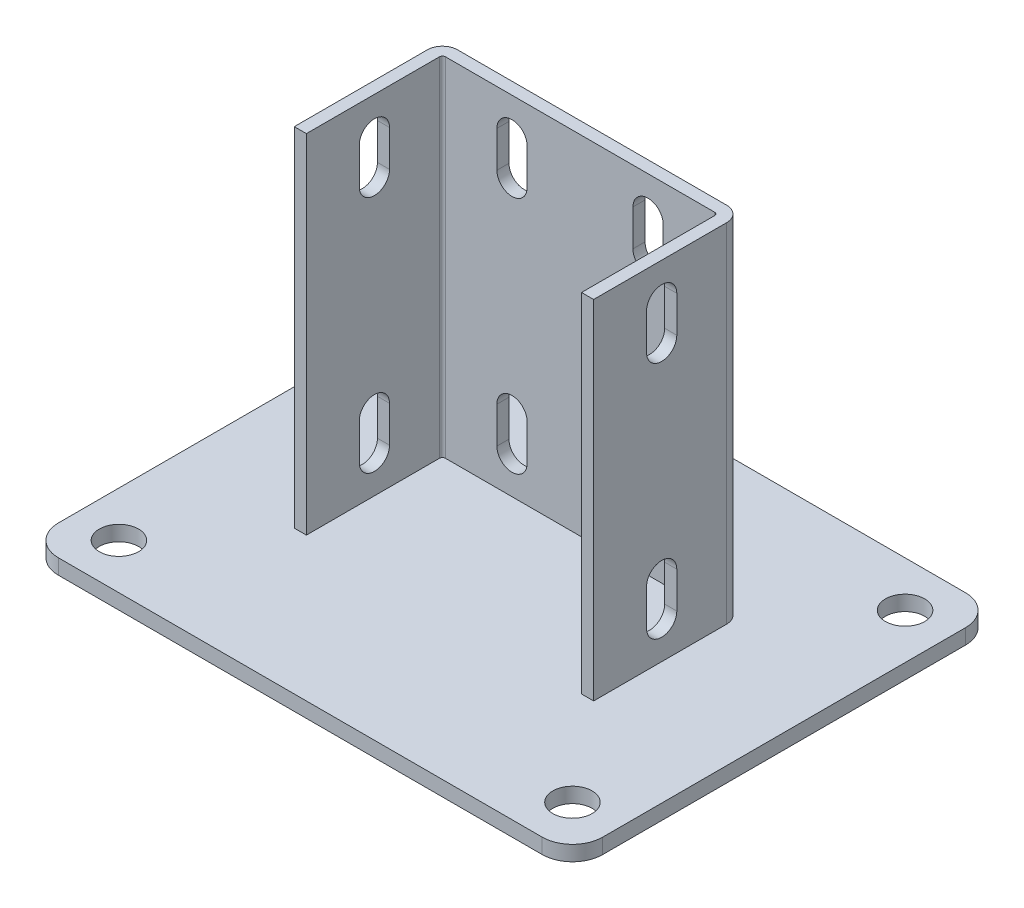
from build123d import *

# Parameters (mm, degrees)
SKETCH_2_W          = 180
SKETCH_2_H          = 140
EXTRUDE_1_DEPTH     = 5
EXTRUDE_1_2_DEPTH   = 115
EXTRUDE_2_DEPTH     = 2
CUT_EXTRUDE_1_DEPTH = 140.5
SKETCH_6_R          = 6.5
CUT_EXTRUDE_2_DEPTH = 6
FILLET_1_R          = 10
CUT_EXTRUDE_3_REACH = 98.5


with BuildPart() as part:
    # Эскиз2 → Extrude 1 (new body)
    with BuildSketch(Plane(origin=(0, 0, 0), x_dir=(1, 0, 0), z_dir=(0, 1, 0))):
        Rectangle(SKETCH_2_W, SKETCH_2_H)
    extrude(amount=EXTRUDE_1_DEPTH)

    # Эскиз3 → Extrude 1 2 (add)
    with BuildSketch(Plane(origin=(0, 5, 0), x_dir=(1, 0, 0), z_dir=(0, 1, 0))):
        with BuildLine():
            Line((-45.5, -22.5), (-45.5, 21.5))
            ThreePointArc((-45.5, 21.5), (-45.207106781, 22.207106781), (-44.5, 22.5))
            Line((-44.5, 22.5), (44.5, 22.5))
            ThreePointArc((44.5, 22.5), (45.207106781, 22.207106781), (45.5, 21.5))
            Line((45.5, 21.5), (45.5, -22.5))
            Line((45.5, -22.5), (49.5, -22.5))
            Line((49.5, -22.5), (49.5, 21.5))
            ThreePointArc((49.5, 21.5), (48.035533906, 25.035533906), (44.5, 26.5))
            Line((44.5, 26.5), (-44.5, 26.5))
            ThreePointArc((-44.5, 26.5), (-48.035533906, 25.035533906), (-49.5, 21.5))
            Line((-49.5, 21.5), (-49.5, -22.5))
            Line((-49.5, -22.5), (-45.5, -22.5))
        make_face()
    extrude(amount=EXTRUDE_1_2_DEPTH)

    # Эскиз4 → Бобышка-Вытянуть2 (add, symmetric)
    with BuildSketch(Plane(origin=(0, 0, 0), x_dir=(0, 0, -1), z_dir=(1, 0, 0))):
        Polygon((26.5, 71.683956091), (65, 5), (26.5, 5), align=None)
    extrude(amount=EXTRUDE_2_DEPTH, both=True)

    # Эскиз5 → Вырез-Вытянуть1 (cut, through all)
    with BuildSketch(Plane(origin=(49.5, 0, 0), x_dir=(0, 0, -1), z_dir=(1, 0, 0))):
        with BuildLine():
            Line((5, 108), (5, 96))
            ThreePointArc((5, 96), (0, 91), (-5, 96))
            Line((-5, 96), (-5, 108))
            ThreePointArc((-5, 108), (0, 113), (5, 108))
        make_face()
        with BuildLine():
            Line((5, 29), (5, 17))
            ThreePointArc((5, 17), (0, 12), (-5, 17))
            Line((-5, 17), (-5, 29))
            ThreePointArc((-5, 29), (0, 34), (5, 29))
        make_face()
    extrude(amount=-CUT_EXTRUDE_1_DEPTH, mode=Mode.SUBTRACT)

    # Эскиз6 → Вырез-Вытянуть2 (cut, through all)
    with BuildSketch(Plane(origin=(0, 5, 0), x_dir=(1, 0, 0), z_dir=(0, 1, 0))):
        with Locations(Location((-75, 55, 0), (0, 0, 270))):  # turned: the seam where the file's is
            Circle(SKETCH_6_R)
        with Locations(Location((-75, -55, 0), (0, 0, 270))):  # turned: the seam where the file's is
            Circle(SKETCH_6_R)
        with Locations(Location((75, 55, 0), (0, 0, 270))):  # turned: the seam where the file's is
            Circle(SKETCH_6_R)
        with Locations(Location((75, -55, 0), (0, 0, 270))):  # turned: the seam where the file's is
            Circle(SKETCH_6_R)
    extrude(amount=-CUT_EXTRUDE_2_DEPTH, mode=Mode.SUBTRACT)

    # Скругление1
    fillet_1_edges = [part.edges().sort_by_distance(p)[0] for p in [
        (90, 2.5, 70),
        (-90, 2.5, 70),
        (-90, 2.5, -70),
        (90, 2.5, -70),
    ]]
    fillet(fillet_1_edges, radius=FILLET_1_R)

    # Эскиз8 → Вырез-Вытянуть3 (cut, up to next)
    with BuildSketch(Plane(origin=(0, 0, -26.5), x_dir=(-1, 0, 0), z_dir=(0, 0, -1)), mode=Mode.PRIVATE) as cut_extrude_3_sk1:
        with BuildLine():
            Line((-17.5, 108), (-17.5, 96))
            ThreePointArc((-17.5, 96), (-22.5, 91), (-27.5, 96))
            Line((-27.5, 96), (-27.5, 108))
            ThreePointArc((-27.5, 108), (-22.5, 113), (-17.5, 108))
        make_face()
    cut_extrude_3_tool1 = extrude(cut_extrude_3_sk1.sketch, amount=-CUT_EXTRUDE_3_REACH, mode=Mode.PRIVATE) & part.part
    add(cut_extrude_3_tool1.solids().sort_by_distance((22.5, 102, -26.5))[0], mode=Mode.SUBTRACT)
    # Эскиз8 → Вырез-Вытянуть3 (cut, up to next)
    with BuildSketch(Plane(origin=(0, 0, -26.5), x_dir=(-1, 0, 0), z_dir=(0, 0, -1)), mode=Mode.PRIVATE) as cut_extrude_3_sk2:
        with BuildLine():
            Line((-17.5, 29), (-17.5, 17))
            ThreePointArc((-17.5, 17), (-22.5, 12), (-27.5, 17))
            Line((-27.5, 17), (-27.5, 29))
            ThreePointArc((-27.5, 29), (-22.5, 34), (-17.5, 29))
        make_face()
    cut_extrude_3_tool2 = extrude(cut_extrude_3_sk2.sketch, amount=-CUT_EXTRUDE_3_REACH, mode=Mode.PRIVATE) & part.part
    add(cut_extrude_3_tool2.solids().sort_by_distance((22.5, 23, -26.5))[0], mode=Mode.SUBTRACT)
    # Эскиз8 → Вырез-Вытянуть3 (cut, up to next)
    with BuildSketch(Plane(origin=(0, 0, -26.5), x_dir=(-1, 0, 0), z_dir=(0, 0, -1)), mode=Mode.PRIVATE) as cut_extrude_3_sk3:
        with BuildLine():
            Line((17.5, 108), (17.5, 96))
            ThreePointArc((17.5, 96), (22.5, 91), (27.5, 96))
            Line((27.5, 96), (27.5, 108))
            ThreePointArc((27.5, 108), (22.5, 113), (17.5, 108))
        make_face()
    cut_extrude_3_tool3 = extrude(cut_extrude_3_sk3.sketch, amount=-CUT_EXTRUDE_3_REACH, mode=Mode.PRIVATE) & part.part
    add(cut_extrude_3_tool3.solids().sort_by_distance((-22.5, 102, -26.5))[0], mode=Mode.SUBTRACT)
    # Эскиз8 → Вырез-Вытянуть3 (cut, up to next)
    with BuildSketch(Plane(origin=(0, 0, -26.5), x_dir=(-1, 0, 0), z_dir=(0, 0, -1)), mode=Mode.PRIVATE) as cut_extrude_3_sk4:
        with BuildLine():
            Line((17.5, 29), (17.5, 17))
            ThreePointArc((17.5, 17), (22.5, 12), (27.5, 17))
            Line((27.5, 17), (27.5, 29))
            ThreePointArc((27.5, 29), (22.5, 34), (17.5, 29))
        make_face()
    cut_extrude_3_tool4 = extrude(cut_extrude_3_sk4.sketch, amount=-CUT_EXTRUDE_3_REACH, mode=Mode.PRIVATE) & part.part
    add(cut_extrude_3_tool4.solids().sort_by_distance((-22.5, 23, -26.5))[0], mode=Mode.SUBTRACT)


solid = part.part
